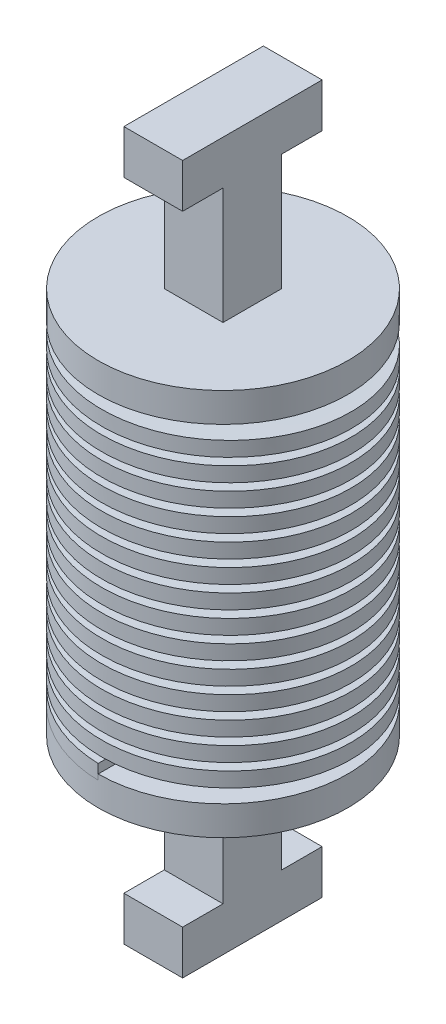
from build123d import *

# Parameters (mm, degrees)
SWEEP1_PITCH         = 1.5
SWEEP1_HEIGHT        = 21.75
SWEEP1_RADIUS        = 7.5
SKETCH4_W            = 4
SKETCH4_H            = 1
SKETCH5_R            = 8.5
BOSS_EXTRUDE1_DEPTH  = 2
SKETCH9_R            = 8.5
BOSS_EXTRUDE8_DEPTH  = 2
SKETCH13_W           = 4
SKETCH13_H           = 4
BOSS_EXTRUDE14_DEPTH = 8
SKETCH18_W           = 9.5
SKETCH18_H           = 3
BOSS_EXTRUDE15_DEPTH = 4
SKETCH15_W           = 4
SKETCH15_H           = 4
BOSS_EXTRUDE16_DEPTH = 8
SKETCH19_W           = 9.5
SKETCH19_H           = 3
BOSS_EXTRUDE17_DEPTH = 4


with BuildPart() as part:
    # Sweep1: sweep along a helix
    with BuildLine() as sweep1_path:
        Helix(SWEEP1_PITCH, SWEEP1_HEIGHT, SWEEP1_RADIUS, center=(0, 0, 0), direction=(0, 1, 0), lefthand=True)
    # Sketch4 → Sweep1 (sweep)
    with BuildSketch(Plane.XY):
        with Locations((-6.5, 0.500000002)):
            Rectangle(SKETCH4_W, SKETCH4_H)
    sweep(path=sweep1_path.line, is_frenet=True)

    # Sketch5 → Boss-Extrude1 (add)
    with BuildSketch(Plane(origin=(0, 0, 0), x_dir=(1, 0, 0), z_dir=(0, 1, 0))):
        Circle(SKETCH5_R)
    extrude(amount=-BOSS_EXTRUDE1_DEPTH)

    # Sketch15 → Boss-Extrude16 (add)
    with BuildSketch(Plane.XZ.offset(2)):
        Rectangle(SKETCH15_W, SKETCH15_H)
    extrude(amount=BOSS_EXTRUDE16_DEPTH)

    # Sketch19 → Boss-Extrude17 (add)
    with BuildSketch(Plane.ZY.offset(2)):
        with Locations((0, -11.405505012)):
            Rectangle(SKETCH19_W, SKETCH19_H)
    extrude(amount=-BOSS_EXTRUDE17_DEPTH)


with BuildPart() as body_2:
    # Sketch9 → Boss-Extrude8 (new body)
    with BuildSketch(Plane(origin=(0, 22.374999994, 0), x_dir=(1, 0, 0), z_dir=(0, 1, 0))):
        Circle(SKETCH9_R)
    extrude(amount=BOSS_EXTRUDE8_DEPTH)

    # Sketch13 → Boss-Extrude14 (add)
    with BuildSketch(Plane(origin=(0, 24.374999994, 0), x_dir=(1, 0, 0), z_dir=(0, 1, 0))):
        Rectangle(SKETCH13_W, SKETCH13_H)
    extrude(amount=BOSS_EXTRUDE14_DEPTH)

    # Sketch18 → Boss-Extrude15 (add)
    with BuildSketch(Plane.ZY.offset(2)):
        with Locations((0, 33.808693384)):
            Rectangle(SKETCH18_W, SKETCH18_H)
    extrude(amount=-BOSS_EXTRUDE15_DEPTH)


solid = Compound([part.part, body_2.part])
